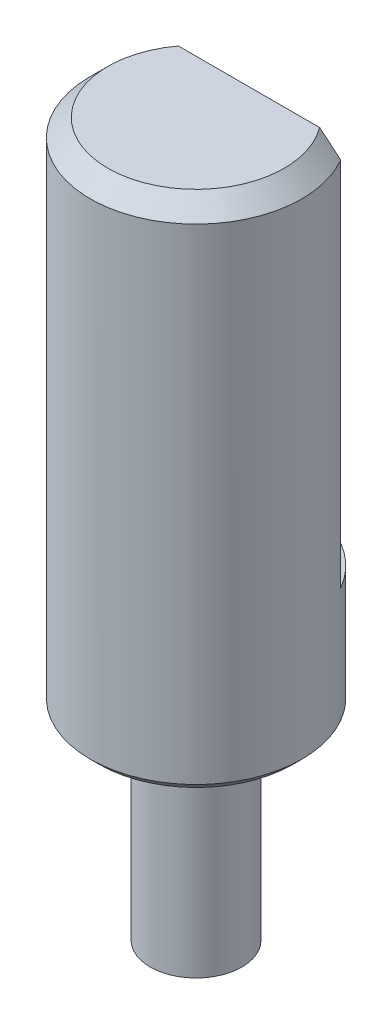
from build123d import *

# Parameters (mm, degrees)
SKETCH_1_R          = 1.3
EXTRUDE_1_DEPTH     = 5.7
SKETCH_2_R          = 3
EXTRUDE_2_DEPTH     = 14.5
CHAMFER_1_SIZE      = 0.25
CUT_EXTRUDE_1_DEPTH = 11
CHAMFER_2_SIZE      = 0.5


with BuildPart() as part:
    # 草图1 → 凸台-拉伸1 (new body)
    with BuildSketch(Plane(origin=(0, 0, 0), x_dir=(1, 0, 0), z_dir=(0, 1, 0))):
        Circle(SKETCH_1_R)
    extrude(amount=EXTRUDE_1_DEPTH)

    # 草图2 → 凸台-拉伸2 (add)
    with BuildSketch(Plane(origin=(0, 5.7, 0), x_dir=(1, 0, 0), z_dir=(0, 1, 0))):
        Circle(SKETCH_2_R)
    extrude(amount=EXTRUDE_2_DEPTH)

    # 倒角1
    chamfer_1_edges = [part.edges().sort_by_distance(p)[0] for p in [
        (-3, 5.7, 0),
    ]]
    chamfer(chamfer_1_edges, length=CHAMFER_1_SIZE)

    # 草图3 → 切除-拉伸1 (cut)
    with BuildSketch(Plane(origin=(0, 20.2, 0), x_dir=(1, 0, 0), z_dir=(0, 1, 0))):
        with BuildLine():
            Line((-2.598076211, 1.5), (2.598076211, 1.5))
            ThreePointArc((2.598076211, 1.5), (0, 3), (-2.598076211, 1.5))
        make_face()
    extrude(amount=-CUT_EXTRUDE_1_DEPTH, mode=Mode.SUBTRACT)

    # 倒角2
    chamfer_2_edges = [part.edges().sort_by_distance(p)[0] for p in [
        (-0.776457135, 20.2, 2.897777479),
    ]]
    chamfer(chamfer_2_edges, length=CHAMFER_2_SIZE)


solid = part.part
